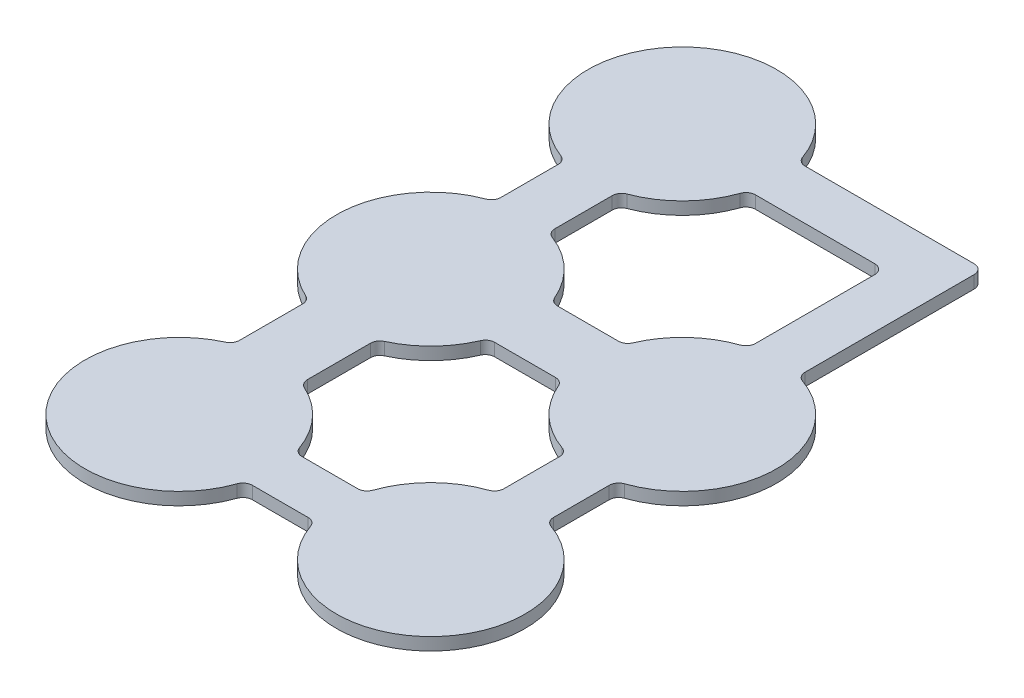
from build123d import *

# Parameters (mm, degrees)
BOSS_EXTRUDE1_DEPTH = 1
FILLET1_R           = 0.75


with BuildPart() as part:
    # Sketch1 → Boss-Extrude1 (new body)
    with BuildSketch(Plane(origin=(0, 0, 0), x_dir=(1, 0, 0), z_dir=(0, 1, 0))):
        with BuildLine():
            ThreePointArc((2.764713205, -21.975), (15.303300859, -25.303300859), (11.975, -12.764713205))
            Line((11.975, -12.764713205), (11.975, -7.235286795))
            ThreePointArc((11.975, -7.235286795), (17.5, 0), (11.975, 7.235286795))
            Line((11.975, 7.235286795), (11.975, 21.975))
            Line((11.975, 21.975), (-2.764713205, 21.975))
            ThreePointArc((-2.764713205, 21.975), (-15.238556982, 25.367263805), (-12.15, 12.814772098))
            Line((-12.15, 12.814772098), (-12.15, 7.185227902))
            ThreePointArc((-12.15, 7.185227902), (-17.494366614, 0.290635598), (-12.7, -6.997142274))
            Line((-12.7, -6.997142274), (-12.7, -13.002857726))
            ThreePointArc((-12.7, -13.002857726), (-15.02663315, -25.566233841), (-2.764713205, -21.975))
            Line((-2.764713205, -21.975), (2.764713205, -21.975))
        make_face()
        with BuildLine():
            Line((8.025, -7.235286795), (8.025, -12.764713205))
            ThreePointArc((8.025, -12.764713205), (4.696699141, -14.696699141), (2.764713205, -18.025))
            Line((2.764713205, -18.025), (-2.764713205, -18.025))
            ThreePointArc((-2.764713205, -18.025), (-4.433766159, -14.97336685), (-7.3, -13.002857726))
            Line((-7.3, -13.002857726), (-7.3, -6.997142274))
            ThreePointArc((-7.3, -6.997142274), (-4.621848486, -5.22737853), (-2.928932188, -2.5))
            Line((-2.928932188, -2.5), (2.928932188, -2.5))
            ThreePointArc((2.928932188, -2.5), (4.894750646, -5.494217781), (8.025, -7.235286795))
        make_face(mode=Mode.SUBTRACT)
        with BuildLine():
            Line((8.025, 18.025), (8.025, 7.235286795))
            ThreePointArc((8.025, 7.235286795), (4.894750646, 5.494217781), (2.928932188, 2.5))
            Line((2.928932188, 2.5), (-2.928932188, 2.5))
            ThreePointArc((-2.928932188, 2.5), (-4.828456418, 5.431863122), (-7.85, 7.185227902))
            Line((-7.85, 7.185227902), (-7.85, 12.814772098))
            ThreePointArc((-7.85, 12.814772098), (-4.632736195, 14.761443018), (-2.764713205, 18.025))
            Line((-2.764713205, 18.025), (8.025, 18.025))
        make_face(mode=Mode.SUBTRACT)
    extrude(amount=BOSS_EXTRUDE1_DEPTH)

    # Fillet1
    fillet1_edges = [part.edges().sort_by_distance(p)[0] for p in [
        (2.764713205, 0.5, 18.025),
        (-2.764713205, 0.5, 18.025),
        (-2.764713205, 0.5, 21.975),
        (2.764713205, 0.5, 21.975),
        (11.975, 0.5, 12.764713205),
        (11.975, 0.5, 7.235286795),
        (8.025, 0.5, 7.235286795),
        (8.025, 0.5, 12.764713205),
        (-2.928932188, 0.5, 2.5),
        (2.928932188, 0.5, 2.5),
        (2.928932188, 0.5, -2.5),
        (-2.928932188, 0.5, -2.5),
        (11.975, 0.5, -7.235286795),
        (11.975, 0.5, -21.975),
        (-2.764713205, 0.5, -21.975),
        (-2.764713205, 0.5, -18.025),
        (8.025, 0.5, -18.025),
        (8.025, 0.5, -7.235286795),
        (-12.15, 0.5, -12.814772098),
        (-12.15, 0.5, -7.185227902),
        (-7.85, 0.5, -7.185227902),
        (-7.85, 0.5, -12.814772098),
        (-12.7, 0.5, 13.002857726),
        (-12.7, 0.5, 6.997142274),
        (-7.3, 0.5, 6.997142274),
        (-7.3, 0.5, 13.002857726),
    ]]
    fillet(fillet1_edges, radius=FILLET1_R)


solid = part.part
